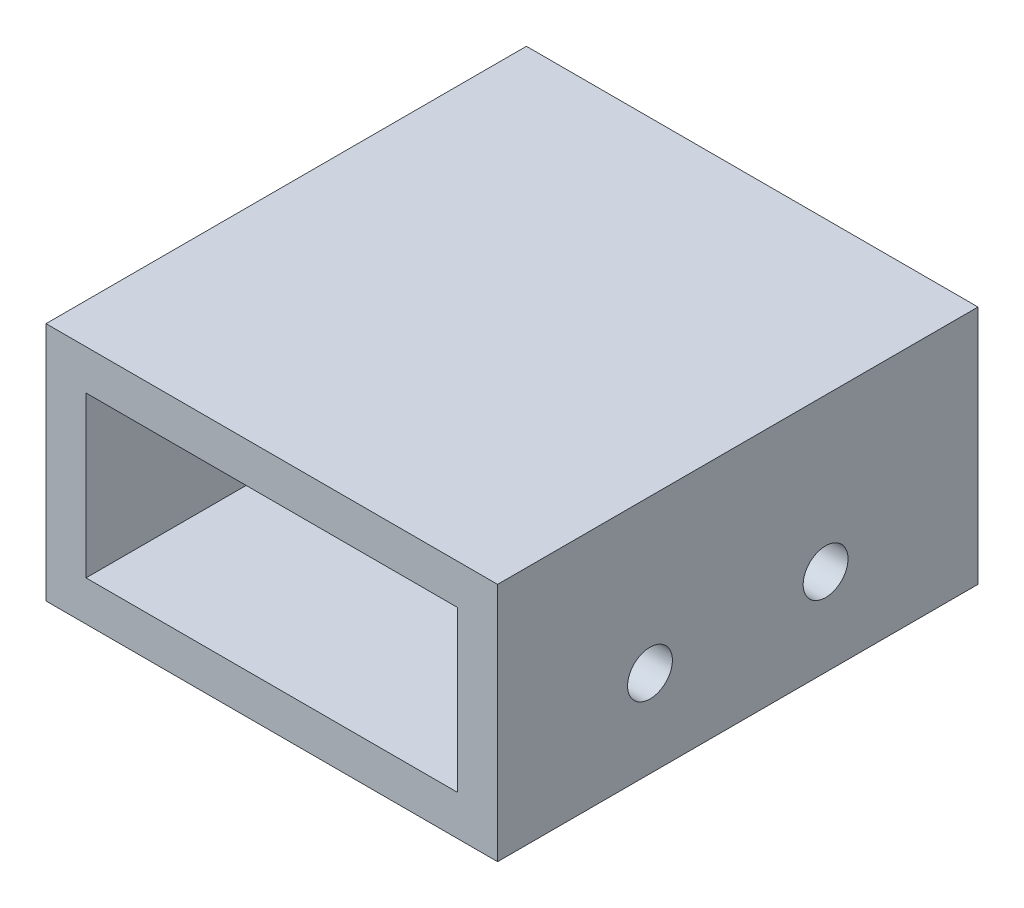
from build123d import *

# Parameters (mm, degrees)
BOSS_EXTRUDE1_DEPTH = 38.1
SKETCH2_R           = 1.778
CUT_EXTRUDE1_DEPTH  = 15.24
SKETCH4_W           = 18.034
SKETCH4_H           = 3.175
BOSS_EXTRUDE2_DEPTH = 38.1
SKETCH3_R           = 1.778
CUT_EXTRUDE2_DEPTH  = 15.24


with BuildPart() as part:
    # Sketch1 → Boss-Extrude1 (new body)
    with BuildSketch(Plane.XY):
        Polygon((0, 0), (0, 19.05), (-35.814, 19.05), (-35.814, 0), (-21.209, 0), (-21.209, 3.175), (-32.639, 3.175), (-32.639, 15.875), (-3.175, 15.875), (-3.175, 0), align=None)
    extrude(amount=-BOSS_EXTRUDE1_DEPTH)

    # Sketch2 → Cut-Extrude1 (cut)
    with BuildSketch(Plane(origin=(0, 0, 0), x_dir=(0, 0, -1), z_dir=(1, 0, 0))):
        with Locations((12.0859042, 6.91388)):
            Circle(SKETCH2_R)
        with Locations((26.0140958, 6.91388)):
            Circle(SKETCH2_R)
    extrude(amount=-CUT_EXTRUDE1_DEPTH, mode=Mode.SUBTRACT)

    # Sketch4 → Boss-Extrude2 (add)
    with BuildSketch(Plane.XY):
        with Locations((-12.192, 1.5875)):
            Rectangle(SKETCH4_W, SKETCH4_H)
    extrude(amount=-BOSS_EXTRUDE2_DEPTH)

    # Sketch3 → Cut-Extrude2 (cut)
    with BuildSketch(Plane(origin=(0, 0, 0), x_dir=(-1, 0, 0), z_dir=(0, -1, 0))):
        with Locations((26.543, 19.05)):
            Circle(SKETCH3_R)
        with Locations((7.747, 19.05)):
            Circle(SKETCH3_R)
    extrude(amount=-CUT_EXTRUDE2_DEPTH, mode=Mode.SUBTRACT)


solid = part.part
